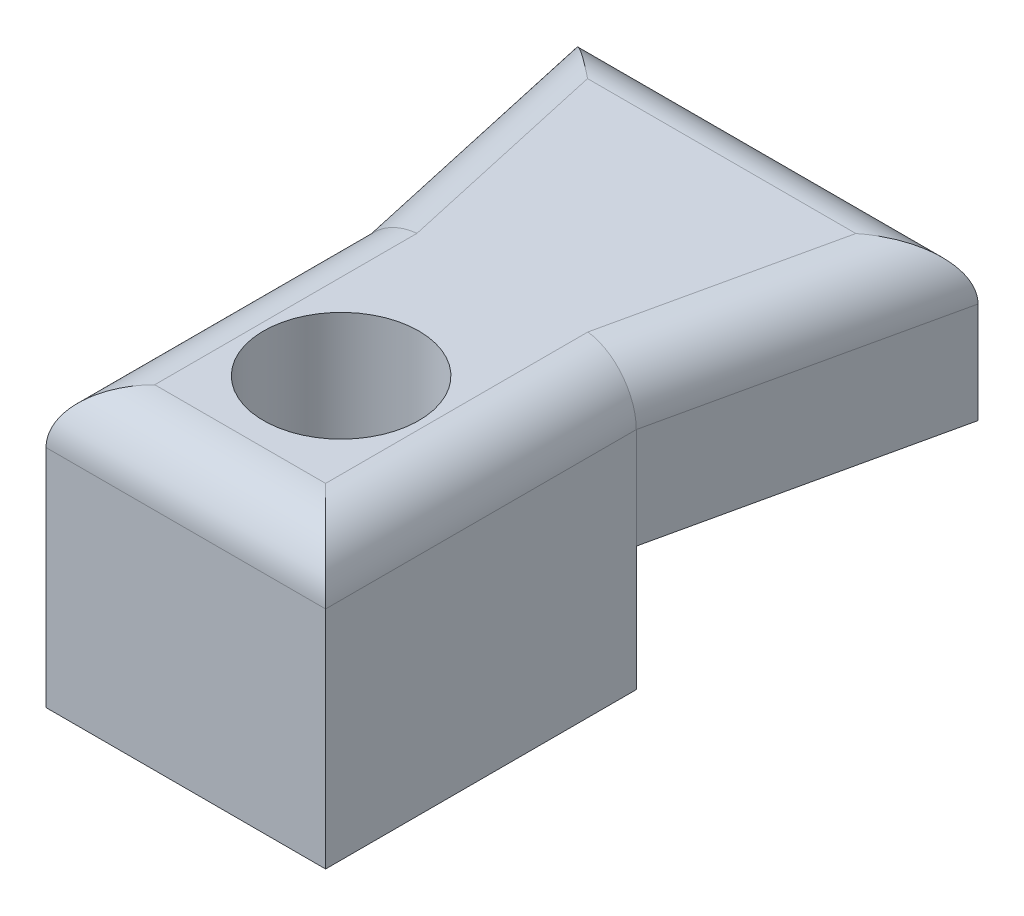
from build123d import *

# Parameters (mm, degrees)
BOSS_EXTRUDE2_DEPTH = 5
SKETCH3_W           = 9
SKETCH3_H           = 10
BOSS_EXTRUDE3_DEPTH = 4
SKETCH4_R           = 2.5
CUT_EXTRUDE1_DEPTH  = 10
FILLET1_R           = 1.75


with BuildPart() as part:
    # Sketch1 → Boss-Extrude2 (new body)
    with BuildSketch(Plane(origin=(0, 0, 0), x_dir=(1, 0, 0), z_dir=(0, 1, 0))):
        Polygon((0, 0), (-2, 9), (11, 9), (9, 0), (9, -10), (0, -10), align=None)
    extrude(amount=BOSS_EXTRUDE2_DEPTH)

    # Sketch3 → Boss-Extrude3 (add)
    with BuildSketch(Plane.XZ):
        with Locations((4.5, 5)):
            Rectangle(SKETCH3_W, SKETCH3_H)
    extrude(amount=BOSS_EXTRUDE3_DEPTH)

    # Sketch4 → Cut-Extrude1 (cut, through all)
    with BuildSketch(Plane.XZ.offset(4)):
        with Locations((4.5, 5)):
            Circle(SKETCH4_R)
    extrude(amount=-CUT_EXTRUDE1_DEPTH, mode=Mode.SUBTRACT)

    # Fillet1
    fillet1_edges = [part.edges().sort_by_distance(p)[0] for p in [
        (9, 5, 5),
        (10, 5, -4.5),
        (4.5, 5, -9),
        (-1, 5, -4.5),
        (0, 5, 5),
        (4.5, 5, 10),
    ]]
    fillet(fillet1_edges, radius=FILLET1_R)


solid = part.part
